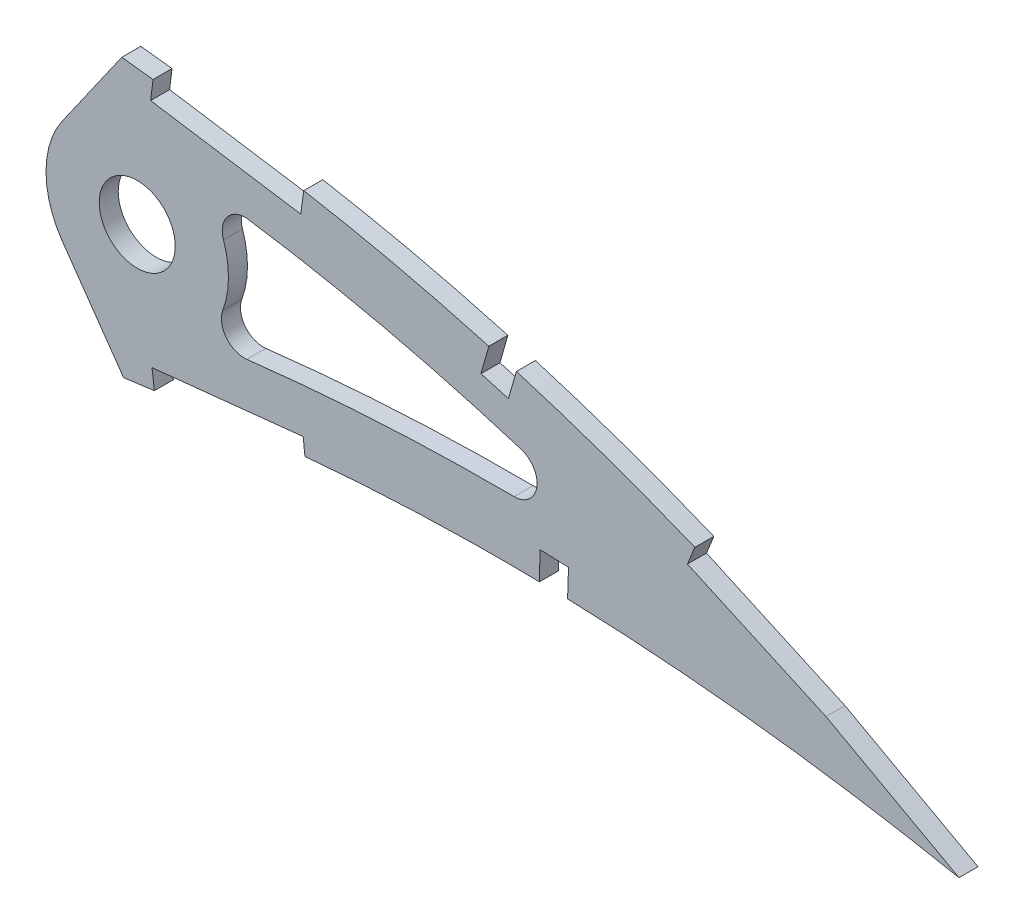
from build123d import *

# Parameters (mm, degrees)
BOSS_EXTRUDE1_DEPTH = 3.175
SKETCH3_R           = 6.35
CUT_EXTRUDE2_DEPTH  = 7.62
CUT_EXTRUDE3_DEPTH  = 443.627115857
CUT_EXTRUDE4_DEPTH  = 442.924727794
FILLET1_R           = 3.81


with BuildPart() as part:
    # Sketch1 → Boss-Extrude1 (new body)
    with BuildSketch(Plane.XY):
        with BuildLine():
            Line((435.33010469, 0.678691456), (439.172882547, -1.614212492))
            Line((439.172882547, -1.614212492), (434.787151486, -0.678691456))
            add(Edge.make_bspline(
                [(0, 0), (0.11179123, -0.527729161), (0.335887463, -1.58561283), (0.94472768, -3.108527015), (1.749889805, -4.572488672), (2.768272335, -5.973609192), (3.993104005, -7.311505618), (5.421679636, -8.587569541), (7.052598221, -9.801114861), (8.883725224, -10.951589231), (10.912400596, -12.040213999), (13.136344152, -13.066312264), (15.553528081, -14.029563428), (18.161318821, -14.928679795), (20.956528242, -15.765030781), (23.936498821, -16.536578215), (27.097842034, -17.244400464), (30.437517266, -17.886690773), (33.951885298, -18.464101669), (37.637295209, -18.976309975), (41.489964184, -19.423636044), (45.506112459, -19.80514129), (49.681767661, -20.121646285), (54.012767863, -20.373360955), (58.494909036, -20.561083494), (63.123897762, -20.684100336), (67.895200479, -20.744329207), (72.804505265, -20.742674403), (77.847009648, -20.678693244), (83.018406129, -20.555920262), (88.313732191, -20.373577887), (93.728207214, -20.133872554), (99.256947275, -19.839216685), (104.89499369, -19.49060908), (110.637384794, -19.089594814), (116.479134607, -18.639389777), (122.414936441, -18.141116951), (128.439613477, -17.597680601), (134.547832047, -17.011801372), (140.734314746, -16.385333349), (146.993600903, -15.721223571), (153.320115485, -15.021624036), (159.708476563, -14.290267097), (166.152848405, -13.528475979), (172.647781594, -12.740600204), (179.187166024, -11.928145018), (185.765533466, -11.094239816), (192.376967293, -10.242811017), (199.015278084, -9.37376151), (205.674882543, -8.493282903), (212.349358377, -7.600650086), (219.032895906, -6.7004538), (225.719308248, -5.795492203), (232.402082768, -4.886043807), (239.075345122, -3.975877517), (245.732904616, -3.06749205), (252.368240069, -2.160970285), (258.975348295, -1.26081803), (265.547576185, -0.366925322), (272.078863439, 0.518895586), (278.562951189, 1.394000598), (284.993721977, 2.257285217), (291.364542133, 3.108203268), (297.66900214, 3.947074317), (303.806375969, 4.748436439), (309.760626579, 5.554962658), (315.551818652, 6.216135275), (321.27090305, 6.780469964), (326.923820465, 7.243146515), (332.503782957, 7.610821489), (338.004397185, 7.886122043), (343.419107553, 8.072891719), (348.74107448, 8.176671364), (353.963650696, 8.200094537), (359.079707468, 8.150631139), (364.082590991, 8.032268225), (368.965318868, 7.850318702), (373.721079318, 7.610921079), (378.343117125, 7.320601554), (382.824493294, 6.983642622), (387.158963185, 6.607910686), (391.339839301, 6.198906082), (395.360701925, 5.761301701), (399.215684034, 5.304267166), (402.898615263, 4.830811549), (406.403955911, 4.348715399), (409.726063296, 3.862864382), (412.859676284, 3.379461168), (415.799871302, 2.903117573), (418.541899149, 2.440155772), (421.081464376, 1.994901374), (423.414160264, 1.571702591), (425.536750687, 1.175899009), (427.445043551, 0.809456817), (429.136486586, 0.478415007), (430.607934716, 0.184234372), (431.857230885, -0.068940506), (432.88219343, -0.280110359), (433.681265576, -0.445808771), (434.252869013, -0.566300363), (434.596385478, -0.637999126), (434.749014267, -0.670556399), (434.787151486, -0.678691456)],
                knots=[0, 0, 0, 0, 0.003638255, 0.007293231, 0.011028136, 0.014901081, 0.018963272, 0.023258475, 0.027820626, 0.032679082, 0.03785316, 0.043361875, 0.049214679, 0.055422346, 0.061988786, 0.068918036, 0.076211157, 0.083868392, 0.091887411, 0.100265912, 0.108999867, 0.118084529, 0.127514843, 0.13728527, 0.147387917, 0.157816481, 0.168563473, 0.179619128, 0.190977373, 0.202626974, 0.214560478, 0.226767249, 0.239236417, 0.251959004, 0.264923894, 0.278119703, 0.291536035, 0.30516028, 0.318980685, 0.332985499, 0.34716279, 0.361498603, 0.375980747, 0.390597192, 0.405332593, 0.420174823, 0.435109533, 0.450124276, 0.465203068, 0.480333154, 0.495500583, 0.510689775, 0.525887334, 0.541078314, 0.556247233, 0.571381785, 0.58646604, 0.601484515, 0.616424329, 0.631269423, 0.646006524, 0.660620684, 0.675098187, 0.689422858, 0.703581825, 0.716907563, 0.730009274, 0.742952128, 0.755725557, 0.768319951, 0.780724337, 0.792926528, 0.804916041, 0.816679084, 0.828203525, 0.8394749, 0.850481359, 0.861207697, 0.871639326, 0.881763414, 0.891563605, 0.901027365, 0.910138977, 0.918883977, 0.927249278, 0.935221104, 0.942784739, 0.949928188, 0.956638465, 0.962904203, 0.968712288, 0.974054485, 0.978918432, 0.983297219, 0.987180246, 0.990560674, 0.993433357, 0.995790626, 0.997629588, 0.998945816, 0.999736592, 1, 1, 1, 1], degree=3))
            add(Edge.make_bspline(
                [(435.33010469, 0.678691456), (435.296755582, 0.699293055), (435.163488681, 0.781619431), (434.863214309, 0.965803828), (434.363194901, 1.272571896), (433.663211466, 1.69979322), (432.763807452, 2.246333125), (431.664530435, 2.908364558), (430.366066728, 3.683736897), (428.86873043, 4.568782589), (427.172675107, 5.559358025), (425.278546429, 6.651449737), (423.186509465, 7.838875427), (420.897374442, 9.116782681), (418.411926851, 10.4790944), (415.730636684, 11.919657082), (412.854464224, 13.43114364), (409.784513475, 15.00705265), (406.521344218, 16.638681918), (403.066494801, 18.319240705), (399.421116368, 20.040349747), (395.586453278, 21.79282696), (391.56470833, 23.569527811), (387.356993489, 25.359407096), (382.965706604, 27.15470981), (378.392717175, 28.945218407), (373.640732922, 30.722778715), (368.711587102, 32.475875028), (363.608964359, 34.196846251), (358.335340013, 35.87451254), (352.894485425, 37.499762392), (347.289561815, 39.062058655), (341.52524157, 40.553388886), (335.605180365, 41.962892679), (329.534395845, 43.28113527), (323.317713598, 44.500180123), (316.960347344, 45.607856696), (310.479914041, 46.603301327), (303.980682286, 47.431342852), (297.494822244, 48.243461645), (291.0186212, 49.006373108), (284.46326746, 49.736966294), (277.835067652, 50.431127833), (271.140596349, 51.086687253), (264.386630807, 51.700815013), (257.580189535, 52.27171033), (250.727858804, 52.796138155), (243.836864005, 53.273290553), (236.914017847, 53.698972807), (229.966694004, 54.072865307), (223.001944897, 54.392360355), (216.027018499, 54.655256617), (209.049321182, 54.859966995), (202.076096041, 55.004530305), (195.114893299, 55.088037667), (188.172953688, 55.108207309), (181.257823923, 55.064678381), (174.376745271, 54.95595632), (167.537272154, 54.780552763), (160.7466557, 54.538140281), (154.012238926, 54.228824112), (147.341395315, 53.850013849), (140.741361553, 53.404123644), (134.219487317, 52.889280335), (127.782938298, 52.305347044), (121.438460058, 51.65475786), (115.193116172, 50.935743156), (109.053599754, 50.150348891), (103.026626206, 49.300114834), (97.118957953, 48.384577869), (91.33692342, 47.406382542), (85.686763085, 46.366529581), (80.174454785, 45.268067638), (74.805999973, 44.111283189), (69.587081438, 42.899646299), (64.52312301, 41.635267927), (59.619568317, 40.320462769), (54.881388132, 38.958385816), (50.313373811, 37.552127128), (45.920850559, 36.103231966), (41.707138151, 34.617193881), (37.677412709, 33.095067788), (33.834761135, 31.541542875), (30.183686712, 29.958740393), (26.726916941, 28.351485511), (23.468364091, 26.721608068), (20.41035055, 25.073674406), (17.555946308, 23.410211446), (14.907899047, 21.73430892), (12.467321746, 20.050217809), (10.237579271, 18.35899521), (8.219437586, 16.664914738), (6.414173801, 14.97055608), (4.824368385, 13.277086383), (3.449964137, 11.587487839), (2.292762263, 9.903098559), (1.352963468, 8.225512409), (0.632693499, 6.555947979), (0.13123808, 4.895344207), (-0.143255259, 3.246152095), (-0.211578297, 1.607049514), (-0.07042072, 0.534882766), (0, 0)],
                knots=[0, 0, 0, 0, 0.00025409, 0.001015373, 0.002283359, 0.004056577, 0.006330982, 0.009105274, 0.012374489, 0.016134023, 0.02037966, 0.025105976, 0.030306237, 0.035972206, 0.042099522, 0.048678064, 0.055701664, 0.063160184, 0.071045824, 0.079349826, 0.08806291, 0.097175756, 0.106678112, 0.116561573, 0.126814275, 0.137428301, 0.148393618, 0.15969976, 0.171338126, 0.183297699, 0.195569604, 0.208143556, 0.221011593, 0.234161831, 0.24758745, 0.261276822, 0.27522271, 0.289414144, 0.303771199, 0.317689227, 0.331784111, 0.346039677, 0.36044387, 0.37498272, 0.389640454, 0.404403316, 0.419256601, 0.434186749, 0.449177265, 0.464214782, 0.479284009, 0.49436974, 0.509457833, 0.524532346, 0.53957932, 0.554582984, 0.569529546, 0.584403417, 0.599190992, 0.613876838, 0.628447475, 0.642888675, 0.657186054, 0.671325546, 0.685294014, 0.699078147, 0.712665095, 0.726042645, 0.739197713, 0.752117586, 0.764792042, 0.777208152, 0.789355685, 0.80122396, 0.812803686, 0.824082909, 0.835054602, 0.845709571, 0.856037853, 0.866033834, 0.875688843, 0.884997719, 0.893953426, 0.902552897, 0.910789386, 0.918660734, 0.926166253, 0.933302626, 0.94007122, 0.94647478, 0.952517526, 0.958204819, 0.963546652, 0.9685566, 0.973249913, 0.977651041, 0.981787043, 0.985694226, 0.989415109, 0.993001157, 0.996508416, 1, 1, 1, 1], degree=3))
        make_face()
    extrude(amount=BOSS_EXTRUDE1_DEPTH)

    # Sketch3 → Cut-Extrude2 (cut)
    with BuildSketch(Plane(origin=(0, 0, 0), x_dir=(-1, 0, 0), z_dir=(0, 0, -1))):
        with Locations((-292.383806588, 26.255421435)):
            Circle(SKETCH3_R)
    extrude(amount=-CUT_EXTRUDE2_DEPTH, mode=Mode.SUBTRACT)

    # Sketch4 → Cut-Extrude3 (cut, through all)
    with BuildSketch(Plane.XY.offset(3.175)):
        with BuildLine():
            ThreePointArc((279.899929433, 17.514116545), (277.143806588, 26.255421435), (279.899929433, 34.996726325))
            Line((279.899929433, 34.996726325), (283.158861137, 39.650963143))
            Line((283.158861137, 39.650963143), (289.801901945, 49.138208631))
            add(Edge.make_bspline(
                [(289.801901945, 49.138208631), (288.030206537, 49.33916957), (284.049324728, 49.780317903), (277.835067652, 50.431127833), (271.140596349, 51.086687253), (264.386630807, 51.700815013), (257.580189535, 52.27171033), (250.727858804, 52.796138155), (243.836864005, 53.273290553), (236.914017847, 53.698972807), (229.966694004, 54.072865307), (223.001944897, 54.392360355), (216.027018499, 54.655256617), (209.049321182, 54.859966995), (202.076096041, 55.004530305), (195.114893299, 55.088037667), (188.172953688, 55.108207309), (181.257823923, 55.064678381), (174.235119629, 54.953718614), (169.519007813, 54.831332674), (167.097214082, 54.75549345)],
                knots=[0.33448194, 0.33448194, 0.33448194, 0.33448194, 0.346039677, 0.36044387, 0.37498272, 0.389640454, 0.404403316, 0.419256601, 0.434186749, 0.449177265, 0.464214782, 0.479284009, 0.49436974, 0.509457833, 0.524532346, 0.53957932, 0.554582984, 0.569529546, 0.584403417, 0.600109109, 0.600109109, 0.600109109, 0.600109109], degree=3))
            add(Edge.make_bspline(
                [(167.097214082, 54.75549345), (164.974251393, 54.689012214), (160.605161128, 54.531641342), (154.012238926, 54.228824112), (147.341395315, 53.850013849), (140.741361553, 53.404123644), (134.219487317, 52.889280335), (127.782938298, 52.305347044), (121.438460058, 51.65475786), (115.193116172, 50.935743156), (109.053599754, 50.150348891), (103.026626206, 49.300114834), (97.118957953, 48.384577869), (91.33692342, 47.406382542), (85.686763085, 46.366529581), (80.174454785, 45.268067638), (74.805999973, 44.111283189), (69.587081438, 42.899646299), (64.52312301, 41.635267927), (59.619568317, 40.320462769), (54.881388132, 38.958385816), (50.313373811, 37.552127128), (45.920850559, 36.103231966), (41.707138151, 34.617193881), (37.677412709, 33.095067788), (33.834761135, 31.541542875), (30.183686712, 29.958740393), (26.726916941, 28.351485511), (23.468364091, 26.721608068), (20.41035055, 25.073674406), (17.555946308, 23.410211446), (14.907899047, 21.73430892), (12.467321746, 20.050217809), (10.237579271, 18.35899521), (8.219437586, 16.664914738), (6.414173801, 14.97055608), (4.824368385, 13.277086383), (3.449964137, 11.587487839), (2.292762263, 9.903098559), (1.352963468, 8.225512409), (0.632693499, 6.555947979), (0.13123808, 4.895344207), (-0.143255259, 3.246152095), (-0.211578297, 1.607049514), (-0.07042072, 0.534882766), (0, 0)],
                knots=[0.600109109, 0.600109109, 0.600109109, 0.600109109, 0.613876838, 0.628447475, 0.642888675, 0.657186054, 0.671325546, 0.685294014, 0.699078147, 0.712665095, 0.726042645, 0.739197713, 0.752117586, 0.764792042, 0.777208152, 0.789355685, 0.80122396, 0.812803686, 0.824082909, 0.835054602, 0.845709571, 0.856037853, 0.866033834, 0.875688843, 0.884997719, 0.893953426, 0.902552897, 0.910789386, 0.918660734, 0.926166253, 0.933302626, 0.94007122, 0.94647478, 0.952517526, 0.958204819, 0.963546652, 0.9685566, 0.973249913, 0.977651041, 0.981787043, 0.985694226, 0.989415109, 0.993001157, 0.996508416, 1, 1, 1, 1], degree=3))
            add(Edge.make_bspline(
                [(0, 0), (0.11179123, -0.527729161), (0.335887463, -1.58561283), (0.94472768, -3.108527015), (1.749889805, -4.572488672), (2.768272335, -5.973609192), (3.993104005, -7.311505618), (5.421679636, -8.587569541), (7.052598221, -9.801114861), (8.883725224, -10.951589231), (10.912400596, -12.040213999), (13.136344152, -13.066312264), (15.553528081, -14.029563428), (18.161318821, -14.928679795), (20.956528242, -15.765030781), (23.936498821, -16.536578215), (27.097842034, -17.244400464), (30.437517266, -17.886690773), (33.951885298, -18.464101669), (37.637295209, -18.976309975), (41.489964184, -19.423636044), (45.506112459, -19.80514129), (49.681767661, -20.121646285), (54.012767863, -20.373360955), (58.494909036, -20.561083494), (63.123897762, -20.684100336), (67.895200479, -20.744329207), (72.804505265, -20.742674403), (77.847009648, -20.678693244), (83.018406129, -20.555920262), (88.313732191, -20.373577887), (93.728207214, -20.133872554), (99.256947275, -19.839216685), (104.89499369, -19.49060908), (110.637384794, -19.089594814), (116.479134607, -18.639389777), (122.414936441, -18.141116951), (128.439613477, -17.597680601), (134.547832047, -17.011801372), (140.734314746, -16.385333349), (146.993600903, -15.721223571), (153.320115485, -15.021624036), (159.708476563, -14.290267097), (166.152848405, -13.528475979), (172.647781594, -12.740600204), (179.187166024, -11.928145018), (184.020593251, -11.315436752), (186.673798255, -10.975876445), (187.133927912, -10.916890365)],
                knots=[0, 0, 0, 0, 0.003638255, 0.007293231, 0.011028136, 0.014901081, 0.018963272, 0.023258475, 0.027820626, 0.032679082, 0.03785316, 0.043361875, 0.049214679, 0.055422346, 0.061988786, 0.068918036, 0.076211157, 0.083868392, 0.091887411, 0.100265912, 0.108999867, 0.118084529, 0.127514843, 0.13728527, 0.147387917, 0.157816481, 0.168563473, 0.179619128, 0.190977373, 0.202626974, 0.214560478, 0.226767249, 0.239236417, 0.251959004, 0.264923894, 0.278119703, 0.291536035, 0.30516028, 0.318980685, 0.332985499, 0.34716279, 0.361498603, 0.375980747, 0.390597192, 0.405332593, 0.420174823, 0.435109533, 0.43824309, 0.43824309, 0.43824309, 0.43824309], degree=3))
            add(Edge.make_bspline(
                [(187.133927912, -10.916890365), (188.878554296, -10.693238901), (192.836937638, -10.182594342), (199.015278084, -9.37376151), (205.674882543, -8.493282903), (212.349358377, -7.600650086), (219.032895906, -6.7004538), (225.719308248, -5.795492203), (232.402082768, -4.886043807), (239.075345122, -3.975877517), (245.732904616, -3.06749205), (252.368240069, -2.160970285), (258.975348295, -1.26081803), (265.547576185, -0.366925322), (272.078863439, 0.518895586), (278.562951189, 1.394000598), (284.566439887, 2.199925677), (288.407934605, 2.713275242), (290.105047048, 2.939698164)],
                knots=[0.43824309, 0.43824309, 0.43824309, 0.43824309, 0.450124276, 0.465203068, 0.480333154, 0.495500583, 0.510689775, 0.525887334, 0.541078314, 0.556247233, 0.571381785, 0.58646604, 0.601484515, 0.616424329, 0.631269423, 0.646006524, 0.660620684, 0.672186056, 0.672186056, 0.672186056, 0.672186056], degree=3))
            Line((290.105047048, 2.939698164), (283.541375038, 12.313593261))
            Line((283.541375038, 12.313593261), (279.899929433, 17.514116545))
        make_face()
        with BuildLine():
            add(Edge.make_bspline(
                [(380.012736873, 17.378520284), (376.536531134, 18.780963315), (367.801866957, 22.125769818), (353.610684457, 26.837765324), (337.391118778, 31.247069735), (323.723539376, 34.153820843), (314.032358556, 35.791182253), (308.541715213, 36.598412959), (305.264114148, 37.024757198), (303.34726967, 37.268572549), (302.852008037, 37.331267155)],
                knots=[0.124948491, 0.124948491, 0.124948491, 0.124948491, 0.150027277, 0.187534097, 0.225040916, 0.262547735, 0.281301145, 0.29067785, 0.300054555, 0.303310606, 0.303310606, 0.303310606, 0.303310606], degree=3))
            ThreePointArc((302.852008037, 37.331267155), (306.380109494, 32.285438429), (307.623806588, 26.255421435))
            ThreePointArc((307.623806588, 26.255421435), (306.273815921, 19.984437404), (302.463013843, 14.8244468))
            add(Edge.make_bspline(
                [(302.463013843, 14.8244468), (303.49267763, 14.961737759), (305.809148029, 15.27238454), (309.550600492, 15.754932076), (313.547342483, 16.211070553), (318.853199564, 16.761525245), (328.189725214, 17.573655052), (341.536325335, 18.286435747), (357.577491589, 18.436704061), (370.403182209, 18.003699572), (377.872990954, 17.531559364), (380.012736873, 17.378520284)],
                knots=[0.703293109, 0.703293109, 0.703293109, 0.703293109, 0.710344093, 0.719121545, 0.727898996, 0.736676448, 0.754231352, 0.789341159, 0.824450965, 0.859560772, 0.873670924, 0.873670924, 0.873670924, 0.873670924], degree=3))
        make_face()
    extrude(amount=-CUT_EXTRUDE3_DEPTH, mode=Mode.SUBTRACT)

    # Sketch5 → Cut-Extrude4 (cut, through all)
    with BuildSketch(Plane.XY.offset(3.175)):
        Polygon((295.010045716, 48.426972341), (294.61729065, 45.27690622), (319.701471788, 41.3956065), (320.127191517, 44.541830034), align=None)
        with BuildLine():
            Line((295.010045716, 48.426972341), (320.127191517, 44.541830034))
            Line((320.127191517, 44.541830034), (320.194428154, 45.038733225))
            add(Edge.make_bspline(
                [(320.194428154, 45.038733225), (319.128614424, 45.224694609), (315.903054771, 45.770265005), (310.479914041, 46.603301327), (303.980682286, 47.431342852), (298.820358024, 48.077486352), (295.855907166, 48.433492826), (295.02318672, 48.532368895)],
                knots=[0.268209845, 0.268209845, 0.268209845, 0.268209845, 0.27522271, 0.289414144, 0.303771199, 0.317689227, 0.323124827, 0.323124827, 0.323124827, 0.323124827], degree=3))
            Line((295.02318672, 48.532368895), (295.010045716, 48.426972341))
        make_face()
        Polygon((351.105156284, 37.940556218), (349.801956767, 33.36043287), (354.382080115, 32.057233348), (355.706760669, 36.593395399), align=None)
        with BuildLine():
            add(Edge.make_bspline(
                [(435.33010469, 0.678691456), (435.296755582, 0.699293055), (435.163488681, 0.781619431), (434.863214309, 0.965803828), (434.363194901, 1.272571896), (433.663211466, 1.69979322), (432.763807452, 2.246333125), (431.664530435, 2.908364558), (430.366066728, 3.683736897), (428.86873043, 4.568782589), (427.172675107, 5.559358025), (425.278546429, 6.651449737), (423.186509465, 7.838875427), (420.897374442, 9.116782681), (418.411926851, 10.4790944), (415.730636684, 11.919657082), (412.854464224, 13.43114364), (409.784513475, 15.00705265), (406.521344218, 16.638681918), (403.066494801, 18.319240705), (399.421116368, 20.040349747), (395.586453278, 21.79282696), (391.56470833, 23.569527811), (388.191009262, 25.00463316), (386.15788, 25.845617825), (385.532953719, 26.10185316)],
                knots=[0, 0, 0, 0, 0.00025409, 0.001015373, 0.002283359, 0.004056577, 0.006330982, 0.009105274, 0.012374489, 0.016134023, 0.02037966, 0.025105976, 0.030306237, 0.035972206, 0.042099522, 0.048678064, 0.055701664, 0.063160184, 0.071045824, 0.079349826, 0.08806291, 0.097175756, 0.106678112, 0.116561573, 0.120939592, 0.120939592, 0.120939592, 0.120939592], degree=3))
            Line((385.532953719, 26.10185316), (385.495890632, 26.010812331))
            Line((385.495890632, 26.010812331), (384.299032723, 23.070880837))
            Line((384.299032723, 23.070880837), (407.426882097, 12.579302446))
            Line((407.426882097, 12.579302446), (429.656239818, 0.374157513))
            add(Edge.make_bspline(
                [(429.656239818, 0.374157513), (429.669838785, 0.371449815), (429.683437622, 0.368741459), (429.697036328, 0.366032451)],
                knots=[0.988206312, 0.988206312, 0.988206312, 0.988206312, 0.988299975, 0.988299975, 0.988299975, 0.988299975], degree=3))
            add(Edge.make_bspline(
                [(429.697036328, 0.366032451), (430.025263228, 0.300646146), (430.770398274, 0.151310481), (431.857230885, -0.068940506), (432.88219343, -0.280110359), (433.681265576, -0.445808771), (434.252869013, -0.566300363), (434.596385478, -0.637999126), (434.749014267, -0.670556399), (434.787151486, -0.678691456)],
                knots=[0.988299975, 0.988299975, 0.988299975, 0.988299975, 0.990560674, 0.993433357, 0.995790626, 0.997629588, 0.998945816, 0.999736592, 1, 1, 1, 1], degree=3))
            Line((434.787151486, -0.678691456), (439.172882547, -1.614212492))
            Line((439.172882547, -1.614212492), (435.33010469, 0.678691456))
        make_face()
        with BuildLine():
            Line((388.422380066, 33.199366948), (385.532953719, 26.10185316))
            add(Edge.make_bspline(
                [(435.33010469, 0.678691456), (435.296755582, 0.699293055), (435.163488681, 0.781619431), (434.863214309, 0.965803828), (434.363194901, 1.272571896), (433.663211466, 1.69979322), (432.763807452, 2.246333125), (431.664530435, 2.908364558), (430.366066728, 3.683736897), (428.86873043, 4.568782589), (427.172675107, 5.559358025), (425.278546429, 6.651449737), (423.186509465, 7.838875427), (420.897374442, 9.116782681), (418.411926851, 10.4790944), (415.730636684, 11.919657082), (412.854464224, 13.43114364), (409.784513475, 15.00705265), (406.521344218, 16.638681918), (403.066494801, 18.319240705), (399.421116368, 20.040349747), (395.586453278, 21.79282696), (391.56470833, 23.569527811), (388.191009262, 25.00463316), (386.15788, 25.845617825), (385.532953719, 26.10185316)],
                knots=[0, 0, 0, 0, 0.00025409, 0.001015373, 0.002283359, 0.004056577, 0.006330982, 0.009105274, 0.012374489, 0.016134023, 0.02037966, 0.025105976, 0.030306237, 0.035972206, 0.042099522, 0.048678064, 0.055701664, 0.063160184, 0.071045824, 0.079349826, 0.08806291, 0.097175756, 0.106678112, 0.116561573, 0.120939592, 0.120939592, 0.120939592, 0.120939592], degree=3))
            Line((435.33010469, 0.678691456), (439.172882547, -1.614212492))
            Line((439.172882547, -1.614212492), (434.787151486, -0.678691456))
            add(Edge.make_bspline(
                [(429.697036328, 0.366032451), (430.025263228, 0.300646146), (430.770398274, 0.151310481), (431.857230885, -0.068940506), (432.88219343, -0.280110359), (433.681265576, -0.445808771), (434.252869013, -0.566300363), (434.596385478, -0.637999126), (434.749014267, -0.670556399), (434.787151486, -0.678691456)],
                knots=[0.988299975, 0.988299975, 0.988299975, 0.988299975, 0.990560674, 0.993433357, 0.995790626, 0.997629588, 0.998945816, 0.999736592, 1, 1, 1, 1], degree=3))
            Line((429.697036328, 0.366032451), (429.691014272, 0.355064418))
            Line((429.691014272, 0.355064418), (461.874040004, -17.315193912))
            Line((461.874040004, -17.315193912), (461.874040004, 33.199366948))
            Line((461.874040004, 33.199366948), (388.422380066, 33.199366948))
        make_face()
        with BuildLine():
            Line((359.667194083, 12.834100267), (359.5718524, 8.130305825))
            add(Edge.make_bspline(
                [(359.5718524, 8.130305825), (361.088595399, 8.103008177), (362.655147031, 8.064965613), (364.221388875, 8.016808168), (364.271358551, 8.015261443)],
                knots=[0.829227898, 0.829227898, 0.829227898, 0.829227898, 0.8394749, 0.839812599, 0.839812599, 0.839812599, 0.839812599], degree=3))
            Line((364.271358551, 8.015261443), (364.426184526, 12.675946282))
            Line((364.426184526, 12.675946282), (359.667194083, 12.834100267))
        make_face()
        with BuildLine():
            Line((294.854318208, 6.763555783), (295.250229478, 3.624596789))
            add(Edge.make_bspline(
                [(295.250229478, 3.624596789), (296.064663727, 3.732613378), (298.957134083, 4.1152668), (303.806375969, 4.748436439), (309.760626579, 5.554962658), (315.251080031, 6.181800351), (318.786582356, 6.534962106), (320.393081877, 6.684135696)],
                knots=[0.683873275, 0.683873275, 0.683873275, 0.683873275, 0.689422858, 0.703581825, 0.716907563, 0.730009274, 0.740907614, 0.740907614, 0.740907614, 0.740907614], degree=3))
            Line((320.393081877, 6.684135696), (320.105900979, 9.413146666))
            Line((320.105900979, 9.413146666), (294.854318208, 6.763555783))
        make_face()
        with BuildLine():
            add(Edge.make_bspline(
                [(355.723407431, 36.65025707), (354.794995706, 36.927768181), (353.261555963, 37.378409454), (351.724706078, 37.817245349), (351.119103514, 37.988196882)],
                knots=[0.189288635, 0.189288635, 0.189288635, 0.189288635, 0.195569604, 0.199648465, 0.199648465, 0.199648465, 0.199648465], degree=3))
            Line((351.119103514, 37.988196882), (351.105156284, 37.940556218))
            Line((351.105156284, 37.940556218), (355.706760669, 36.593395399))
            Line((355.706760669, 36.593395399), (355.723407431, 36.65025707))
        make_face()
    extrude(amount=-CUT_EXTRUDE4_DEPTH, mode=Mode.SUBTRACT)

    # Fillet1
    fillet1_edges = [part.edges().sort_by_distance(p)[0] for p in [
        (380.012736873, 17.378520284, 1.5875),
        (302.463013843, 14.8244468, 1.5875),
        (302.852008037, 37.331267155, 1.5875),
    ]]
    fillet(fillet1_edges, radius=FILLET1_R)


solid = part.part
